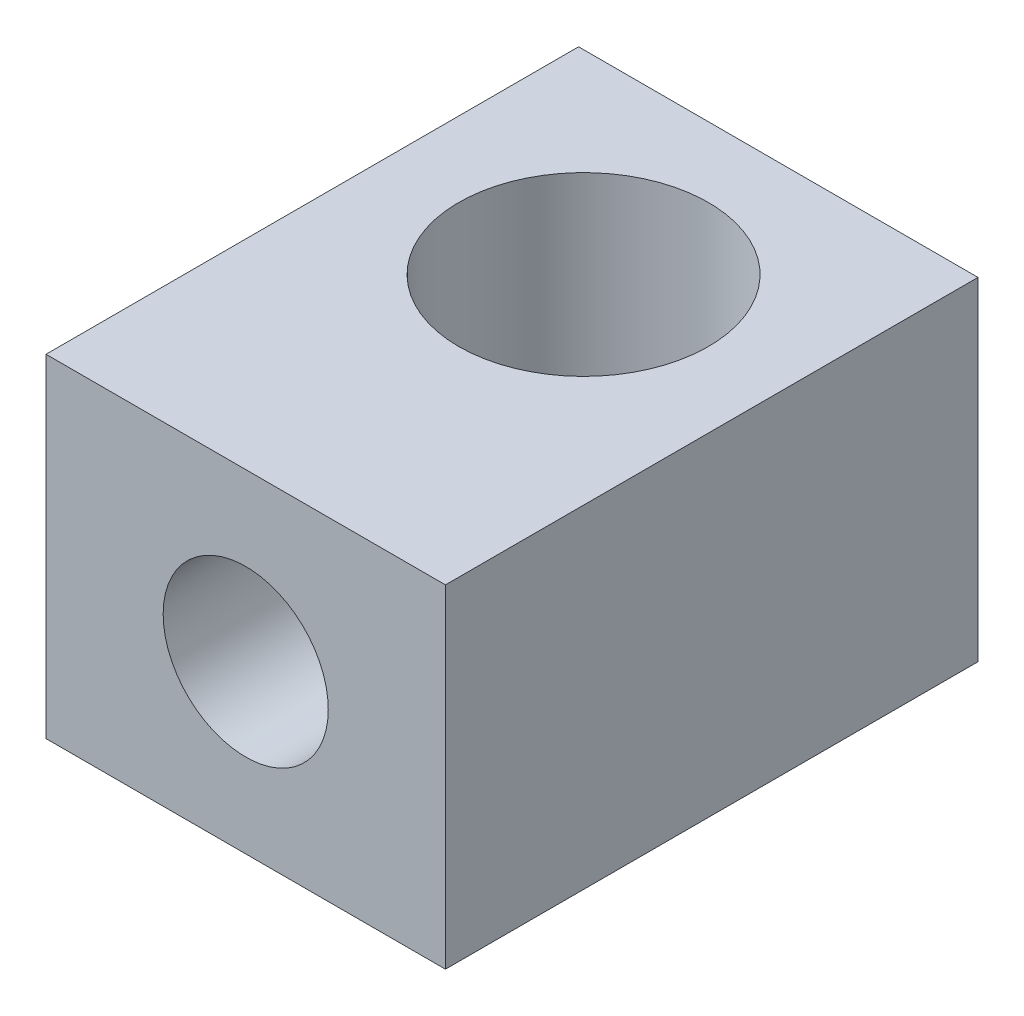
from build123d import *

# Parameters (mm, degrees)
SKETCH1_W           = 60
SKETCH1_H           = 80
SKETCH1_R           = 18.75
BOSS_EXTRUDE1_DEPTH = 25
SKETCH4_R           = 12.4
CUT_EXTRUDE1_DEPTH  = 51.75


with BuildPart() as part:
    # Sketch1 → Boss-Extrude1 (new body, symmetric)
    with BuildSketch(Plane(origin=(0, 0, 0), x_dir=(1, 0, 0), z_dir=(0, 1, 0))):
        with Locations((30, 40)):
            Rectangle(SKETCH1_W, SKETCH1_H)
        with Locations((30, 50.75)):
            Circle(SKETCH1_R, mode=Mode.SUBTRACT)
    extrude(amount=BOSS_EXTRUDE1_DEPTH, both=True)

    # Sketch4 → Cut-Extrude1 (cut, through all)
    with BuildSketch(Plane.XY.offset(-50.75)):
        with Locations((30, 0)):
            Circle(SKETCH4_R)
    extrude(amount=CUT_EXTRUDE1_DEPTH, mode=Mode.SUBTRACT)


solid = part.part
